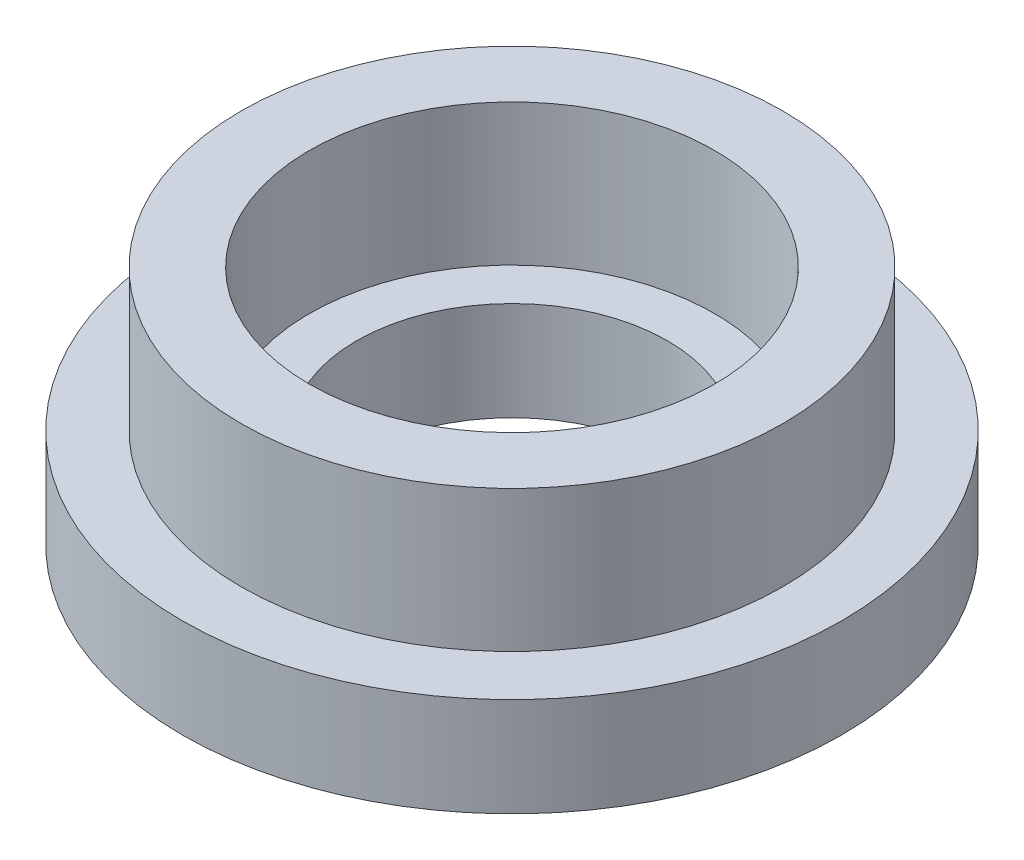
from build123d import *


with BuildPart() as part:
    # Sketch1 → Revolve1 (revolve)
    with BuildSketch(Plane.XY):
        Polygon((-5.75, 3), (-4.3, 3), (-4.3, 0), (-3.3, 0), (-3.3, -2.1), (-7, -2.1), (-7, 0), (-5.75, 0), align=None)
    revolve(axis=Axis((0, 55, 0), (0, -1, 0)))


solid = part.part
